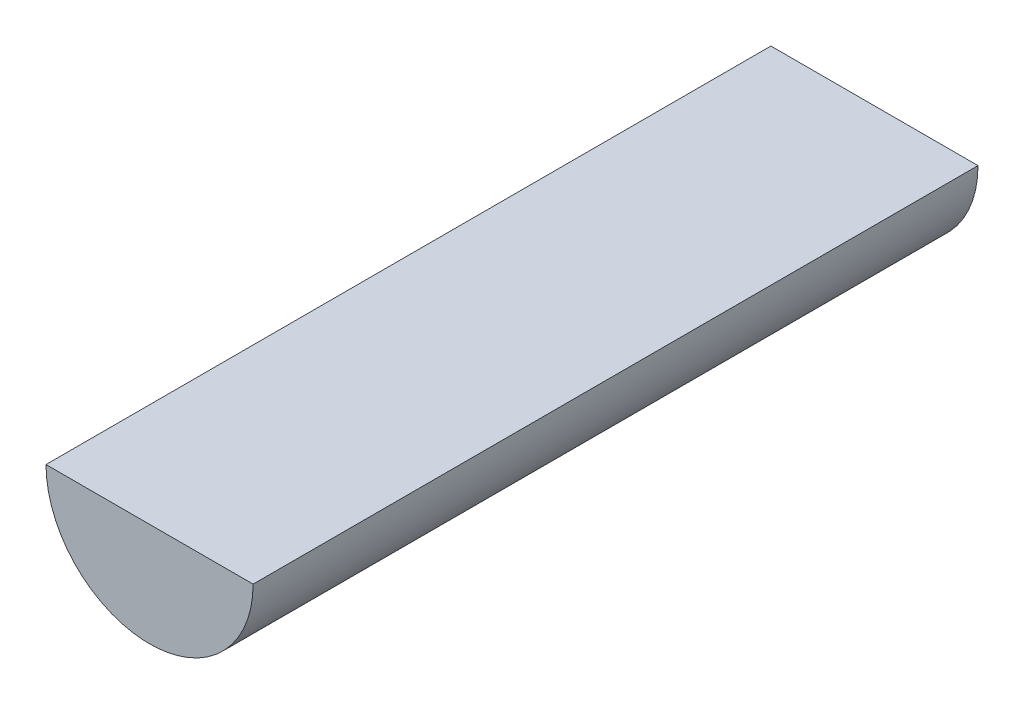
from build123d import *

# Parameters (mm, degrees)
BOSS_EXTRUDE1_DEPTH = 711.2


with BuildPart() as part:
    # Sketch1 → Boss-Extrude1 (new body)
    with BuildSketch(Plane.XY):
        with BuildLine():
            Line((-101.6, 0), (101.6, 0))
            ThreePointArc((101.6, 0), (0, -101.6), (-101.6, 0))
        make_face()
    extrude(amount=BOSS_EXTRUDE1_DEPTH)


solid = part.part
